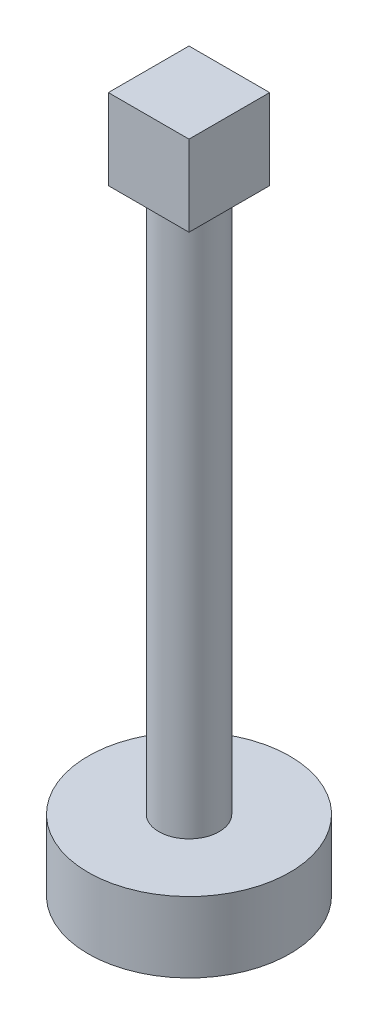
from build123d import *

# Parameters (mm, degrees)
SKETCH1_R           = 50
BOSS_EXTRUDE1_DEPTH = 35
SKETCH2_R           = 15
BOSS_EXTRUDE2_DEPTH = 270
SKETCH3_W           = 40
SKETCH3_H           = 40
BOSS_EXTRUDE3_DEPTH = 40


with BuildPart() as part:
    # Sketch1 → Boss-Extrude1 (new body)
    with BuildSketch(Plane(origin=(0, 0, 0), x_dir=(1, 0, 0), z_dir=(0, 1, 0))):
        Circle(SKETCH1_R)
    extrude(amount=BOSS_EXTRUDE1_DEPTH)

    # Sketch2 → Boss-Extrude2 (add)
    with BuildSketch(Plane(origin=(0, 35, 0), x_dir=(1, 0, 0), z_dir=(0, 1, 0))):
        Circle(SKETCH2_R)
    extrude(amount=BOSS_EXTRUDE2_DEPTH)

    # Sketch3 → Boss-Extrude3 (add)
    with BuildSketch(Plane(origin=(0, 305, 0), x_dir=(1, 0, 0), z_dir=(0, 1, 0))):
        Rectangle(SKETCH3_W, SKETCH3_H)
    extrude(amount=BOSS_EXTRUDE3_DEPTH)


solid = part.part
